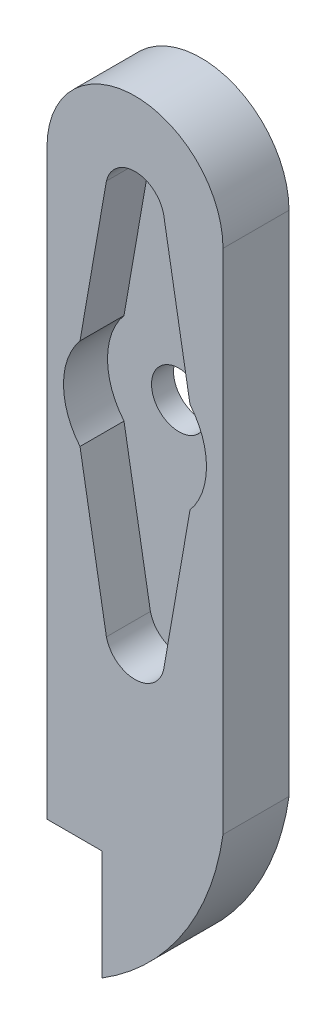
from build123d import *

# Parameters (mm, degrees)
EXTRUDE_1_DEPTH = 6
SKETCH_2_W      = 13.679492917
SKETCH_2_H      = 41.038478751
SKETCH_2_R      = 2.5
EXTRUDE_2_DEPTH = 2


with BuildPart() as part:
    # 草圖1 → 填料-伸長1 (new body)
    with BuildSketch(Plane.XY):
        with BuildLine():
            Line((8, -24.934633195), (8, 17.94275172))
            ThreePointArc((8, 17.94275172), (0, 25.94275172), (-8, 17.94275172))
            Line((-8, 17.94275172), (-8, -18.141285654))
            Line((-8, -18.141285654), (-8, -24.934633195))
            Line((-8, -24.934633195), (-8, -28.206652459))
            Line((-8, -28.206652459), (-8, -35))
            Line((-8, -35), (-3, -35))
            Line((-3, -35), (-3, -45))
            ThreePointArc((-3, -45), (4.367409356, -37.826519096), (8, -28.206652459))
            Line((8, -28.206652459), (8, -24.934633195))
        make_face()
        with BuildLine():
            ThreePointArc((-4.999271035, -4.154189345), (-6.5, 0), (-4.999271035, 4.154189345))
            Line((-4.999271035, 4.154189345), (-2.6, 17.94275172))
            ThreePointArc((-2.6, 17.94275172), (0, 20), (2.6, 17.94275172))
            Line((2.6, 17.94275172), (4.999271035, 4.154189345))
            ThreePointArc((4.999271035, 4.154189345), (6.5, 0), (4.999271035, -4.154189345))
            Line((4.999271035, -4.154189345), (2.6, -17.94275172))
            ThreePointArc((2.6, -17.94275172), (0, -20), (-2.6, -17.94275172))
            Line((-2.6, -17.94275172), (-4.999271035, -4.154189345))
        make_face(mode=Mode.SUBTRACT)
    extrude(amount=EXTRUDE_1_DEPTH)

    # 草圖2 → 填料-伸長2 (add)
    with BuildSketch(Plane.XY):
        with Locations((0.193072501, -0.109084802)):
            Rectangle(SKETCH_2_W, SKETCH_2_H)
        Circle(SKETCH_2_R, mode=Mode.SUBTRACT)
    extrude(amount=EXTRUDE_2_DEPTH)


solid = part.part
